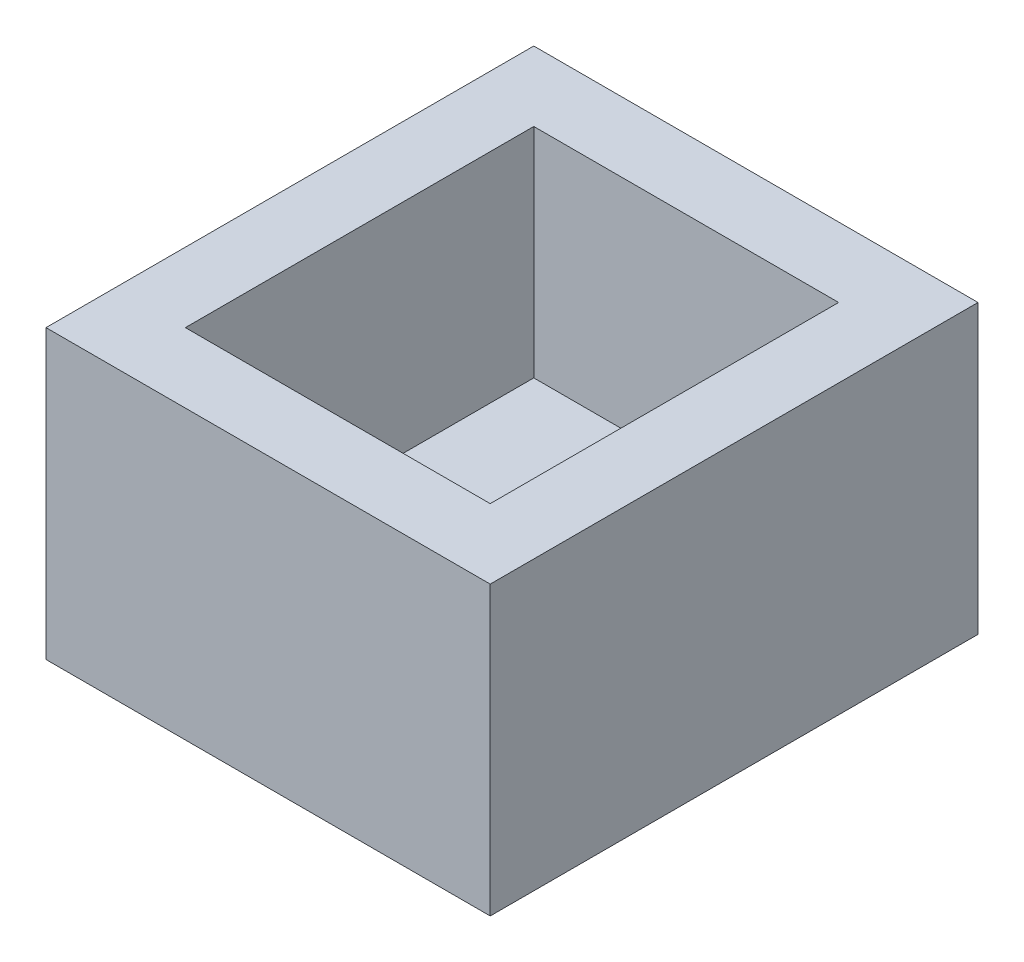
from build123d import *

# Parameters (mm, degrees)
SKETCH4_W           = 102
SKETCH4_H           = 112
BOSS_EXTRUDE4_DEPTH = 16
SKETCH5_W           = 102
SKETCH5_H           = 112
SKETCH5_W_2         = 70
SKETCH5_H_2         = 80
BOSS_EXTRUDE5_DEPTH = 50


with BuildPart() as part:
    # Sketch4 → Boss-Extrude4 (new body)
    with BuildSketch(Plane(origin=(0, 0, 0), x_dir=(1, 0, 0), z_dir=(0, 1, 0))):
        with Locations((51, -56)):
            Rectangle(SKETCH4_W, SKETCH4_H)
    extrude(amount=BOSS_EXTRUDE4_DEPTH)

    # Sketch5 → Boss-Extrude5 (add)
    with BuildSketch(Plane(origin=(0, 16, 0), x_dir=(1, 0, 0), z_dir=(0, 1, 0))):
        with Locations((51, -56)):
            Rectangle(SKETCH5_W, SKETCH5_H)
        with Locations((51, -56)):
            Rectangle(SKETCH5_W_2, SKETCH5_H_2, mode=Mode.SUBTRACT)
    extrude(amount=BOSS_EXTRUDE5_DEPTH)


solid = part.part
